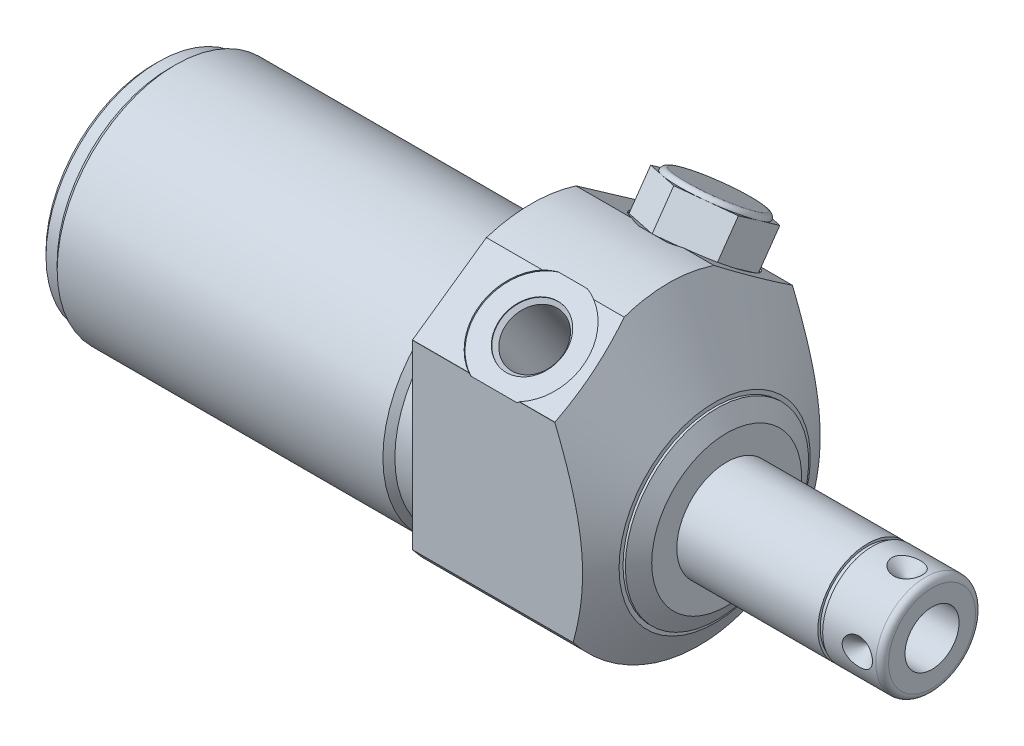
from build123d import *

# Parameters (mm, degrees)
SKETCH1_R           = 25.4
EXTRUDE1_DEPTH      = 31.1404
EXTRUDE1_DEPTH_BACK = 60.1472
CUT_EXTRUDE1_REACH  = 62.147
SKETCH2_R           = 25.4
SKETCH2_R_2         = 18.8595
CUT_EXTRUDE3_REACH  = 93.288
SKETCH4_R           = 25.4
CHAMFER1_SIZE       = 0.762
EXTRUDE2_DEPTH      = 6.78
SKETCH21_W          = 0.762
SKETCH21_H          = 0.381
CIRPATTERN1_COUNT   = 4


with BuildPart() as part:
    # Sketch1 → Extrude1 (new body, two sides)
    with BuildSketch(Plane(origin=(0, 0, 0), x_dir=(0, 0, -1), z_dir=(1, 0, 0))) as extrude1_sk:
        Circle(SKETCH1_R)
    extrude(amount=EXTRUDE1_DEPTH)
    extrude(extrude1_sk.sketch, amount=-EXTRUDE1_DEPTH_BACK)

    # Sketch2 → Cut-Extrude1 (cut, up to next)
    with BuildSketch(Plane(origin=(0, 0, 0), x_dir=(0, 0, -1), z_dir=(1, 0, 0)), mode=Mode.PRIVATE) as cut_extrude1_sk1:
        Circle(SKETCH2_R)
        with Locations((0, -4.191)):
            Circle(SKETCH2_R_2, mode=Mode.SUBTRACT)
    cut_extrude1_tool1 = extrude(cut_extrude1_sk1.sketch, amount=-CUT_EXTRUDE1_REACH, mode=Mode.PRIVATE) & part.part
    add(cut_extrude1_tool1.solids().sort_by_distance((0, 0, 24.68158))[0], mode=Mode.SUBTRACT)

    # Sketch4 → Cut-Extrude3 (cut, up to next)
    with BuildSketch(Plane.ZY.offset(-31.1404), mode=Mode.PRIVATE) as cut_extrude3_sk1:
        Circle(SKETCH4_R)
        with BuildLine():
            Line((18.923, -14.455283714), (18.923, 14.455283714))
            ThreePointArc((18.923, 14.455283714), (18.914286675, 14.466682959), (18.905566483, 14.478076951))
            Line((18.905566483, 14.478076951), (7.138857516, 22.71721527))
            ThreePointArc((7.138857516, 22.71721527), (0, 23.8125), (-7.138857516, 22.71721527))
            Line((-7.138857516, 22.71721527), (-18.905566483, 14.478076951))
            ThreePointArc((-18.905566483, 14.478076951), (-18.914286675, 14.466682959), (-18.923, 14.455283714))
            Line((-18.923, 14.455283714), (-18.923, -14.455283714))
            ThreePointArc((-18.923, -14.455283714), (0, -23.8125), (18.923, -14.455283714))
        make_face(mode=Mode.SUBTRACT)
    cut_extrude3_tool1 = extrude(cut_extrude3_sk1.sketch, amount=CUT_EXTRUDE3_REACH, mode=Mode.PRIVATE) & part.part
    add(cut_extrude3_tool1.solids().sort_by_distance((31.1404, 0, -24.68158))[0], mode=Mode.SUBTRACT)

    # Sketch6 → Cut-Revolve2 (revolve, cut)
    with BuildSketch(Plane.XY, mode=Mode.PRIVATE) as cut_revolve2_sk:
        Polygon((16.382172419, 33.309), (29.2354, 11.046556788), (29.2354, 10.414), (29.600606832, 10.414), (31.1404, 7.747), (31.1404, 33.309), align=None)
    revolve(cut_revolve2_sk.sketch.rotate(Axis((1.987224567, -4.191, 0), (1, 0, 0)), 90), axis=Axis((1.987224567, -4.191, 0), (1, 0, 0)), mode=Mode.SUBTRACT)  # turned: the seam where the file's is

    # S2D0002 → Cut-Revolve3 (revolve, cut)
    with BuildSketch(Plane(origin=(13.0048, 13.712414668, 8.609072086), x_dir=(0, 0.422618262, -0.906307787), z_dir=(1, 0, 0))):
        Polygon((3.058321962, 6.915149075), (6.247621871, 7.477508699), (6.203515233, 7.727649868), (-1.926072768, 6.294184161), (0.455685637, -7.213438979), (4.808141982, -6.445983493), (2.59619413, 6.098596146), (3.080375281, 6.790078491), align=None)
    cut_revolve3 = revolve(axis=Axis((13.0048, 2.978510308, 2.074416081), (0, 0.819152044, 0.573576436)), mode=Mode.SUBTRACT)

    # Mirror1: Cut-Revolve3 across plane
    add(cut_revolve3.mirror(Plane.XY), mode=Mode.SUBTRACT)

    # Sketch10 → Cut-Revolve6 (revolve, cut)
    with BuildSketch(Plane.XY, mode=Mode.PRIVATE) as cut_revolve6_sk:
        Polygon((0, 14.6685), (0, 13.716), (-3.81, 13.716), (-4.7625, 14.6685), align=None)
    revolve(cut_revolve6_sk.sketch.rotate(Axis((-5.09397, -4.191, 0), (1, 0, 0)), 90), axis=Axis((-5.09397, -4.191, 0), (1, 0, 0)), mode=Mode.SUBTRACT)  # turned: the seam where the file's is

    # Sketch12 → Cut-Revolve8 (revolve, cut)
    with BuildSketch(Plane.XY, mode=Mode.PRIVATE) as cut_revolve8_sk:
        Polygon((-60.1472, 14.6685), (-60.1472, 13.716), (-57.6072, 13.716), (-56.6547, 14.6685), align=None)
    revolve(cut_revolve8_sk.sketch.rotate(Axis((-50.92827, -4.191, 0), (1, 0, 0)), 90), axis=Axis((-50.92827, -4.191, 0), (1, 0, 0)), mode=Mode.SUBTRACT)  # turned: the seam where the file's is

    # Chamfer1
    chamfer1_edges = [part.edges().sort_by_distance(p)[0] for p in [
        (-60.1472, -4.191, -17.907),
    ]]
    chamfer(chamfer1_edges, length=CHAMFER1_SIZE)

    # Sketch13 → Revolve1 (revolve)
    with BuildSketch(Plane.XY, mode=Mode.PRIVATE) as revolve1_sk:
        with BuildLine():
            Line((31.1404, -4.191), (63.856, -4.191))
            Line((63.856, -4.191), (63.856, -11.1125))
            ThreePointArc((63.856, -11.1125), (63.55842049, -11.83092049), (62.84, -12.1285))
            Line((62.84, -12.1285), (31.1404, -12.1285))
            Line((31.1404, -12.1285), (31.1404, -4.191))
        make_face()
    revolve(revolve1_sk.sketch.rotate(Axis((4.7498, -4.191, 0), (1, 0, 0)), 270), axis=Axis((4.7498, -4.191, 0), (1, 0, 0)))  # turned: the seam where the file's is

    # S2D0001 → Cut-Revolve9 (revolve, cut)
    with BuildSketch(Plane.XY, mode=Mode.PRIVATE) as cut_revolve9_sk:
        Polygon((63.856, 0.1143), (48.616, 0.1143), (46.029114777, -4.191), (63.856, -4.191), align=None)
    revolve(cut_revolve9_sk.sketch.rotate(Axis((-2.8067, -4.191, 0), (-1, 0, 0)), 270), axis=Axis((-2.8067, -4.191, 0), (-1, 0, 0)), mode=Mode.SUBTRACT)  # turned: the seam where the file's is

    # Sketch15 → Extrude2 (add)
    with BuildSketch(Plane(origin=(0, 18.389581491, -12.876523585), x_dir=(-1, 0, 0), z_dir=(0, 0.819152044, -0.573576436))):
        Polygon((-13.0048, 8.074724416), (-19.9898, 4.041932786), (-19.9898, -4.023650475), (-13.0048, -8.056442105), (-6.0198, -4.023650475), (-6.0198, 4.041932786), align=None)
    extrude(amount=EXTRUDE2_DEPTH)

    # Sketch16 → Cut-Revolve10 (revolve, cut)
    with BuildSketch(Plane(origin=(0, -7.15448452, 0), x_dir=(1, 0, 0), z_dir=(0, 0, -1)), mode=Mode.PRIVATE) as cut_revolve10_sk:
        Polygon((59.8936, -10.90098452), (57.4806, -10.90098452), (59.8936, -8.48798452), align=None)
    cut_revolve10 = revolve(cut_revolve10_sk.sketch.rotate(Axis((59.8936, -3.675688132, 0), (0, -1, 0)), 270), axis=Axis((59.8936, -3.675688132, 0), (0, -1, 0)), mode=Mode.SUBTRACT)  # turned: the seam where the file's is

    # Sketch21 → Cut-Revolve11 (revolve, cut)
    with BuildSketch(Plane.XY, mode=Mode.PRIVATE) as cut_revolve11_sk:
        with Locations((53.9876, 3.556)):
            Rectangle(SKETCH21_W, SKETCH21_H)
    revolve(cut_revolve11_sk.sketch.rotate(Axis((23.873488058, -4.191, 0), (1, 0, 0)), 90), axis=Axis((23.873488058, -4.191, 0), (1, 0, 0)), mode=Mode.SUBTRACT)  # turned: the seam where the file's is

    # Sketch22 → Cut-Revolve12 (revolve, cut)
    with BuildSketch(Plane(origin=(0, 0.005243151, 0.007487996), x_dir=(1, 0, 0), z_dir=(0, 0.573576436, 0.819152044)), mode=Mode.PRIVATE) as cut_revolve12_sk:
        with BuildLine():
            Line((19.9898, 28.467533782), (29.927591051, 28.467533782))
            Line((29.927591051, 28.467533782), (29.927591051, 42.208675473))
            Line((29.927591051, 42.208675473), (19.2278, 42.208675473))
            Line((19.2278, 42.208675473), (19.2278, 29.229533782))
            ThreePointArc((19.2278, 29.229533782), (19.766615367, 29.00634915), (19.9898, 28.467533782))
        make_face()
    revolve(cut_revolve12_sk.sketch.rotate(Axis((13.0048, 2.978510308, -2.074416081), (0, -0.819152044, 0.573576436)), 90), axis=Axis((13.0048, 2.978510308, -2.074416081), (0, -0.819152044, 0.573576436)), mode=Mode.SUBTRACT)  # turned: the seam where the file's is

    # CirPattern1: Cut-Revolve10 ×4 about axis
    cirpattern1_axis = Axis((4.7498, -4.191, 0), (-1, 0, 0))
    for i in range(1, CIRPATTERN1_COUNT):
        add(cut_revolve10.rotate(cirpattern1_axis, i * 360 / CIRPATTERN1_COUNT), mode=Mode.SUBTRACT)


solid = part.part
